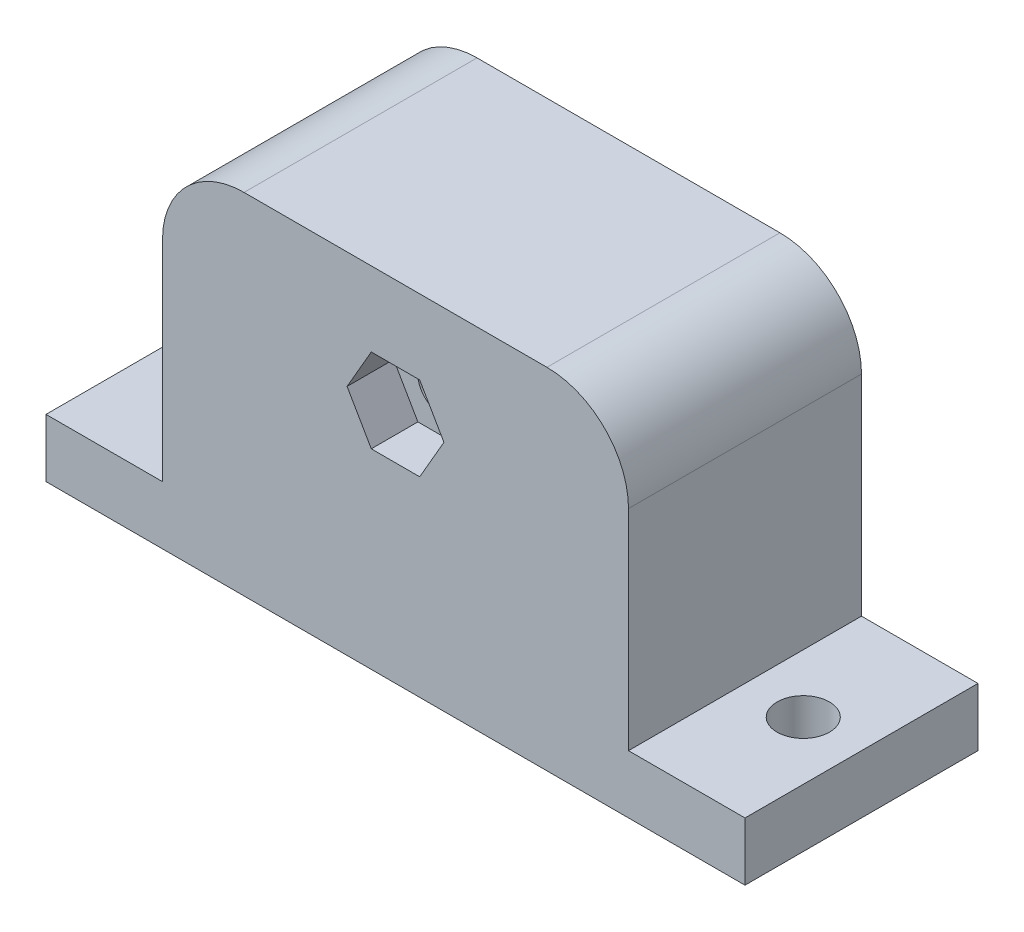
from build123d import *

# Parameters (mm, degrees)
SKETCH1_W               = 60
SKETCH1_H               = 20
SKETCH1_R               = 2.25
BOSS_EXTRUDE1_DEPTH     = 5
SKETCH2_W               = 40
SKETCH2_H               = 20
BOSS_EXTRUDE2_DEPTH     = 25
SKETCH3_R               = 2.1
CUT_EXTRUDE1_DEPTH      = 1
CUT_EXTRUDE1_DEPTH_BACK = 21
SKETCH4_R               = 3.75
CUT_EXTRUDE2_DEPTH      = 5
CUT_EXTRUDE3_DEPTH      = 4
FILLET1_R               = 7


with BuildPart() as part:
    # Sketch1 → Boss-Extrude1 (new body)
    with BuildSketch(Plane(origin=(0, 0, 0), x_dir=(1, 0, 0), z_dir=(0, 1, 0))):
        Rectangle(SKETCH1_W, SKETCH1_H)
        with Locations((-25, 0)):
            Circle(SKETCH1_R, mode=Mode.SUBTRACT)
        with Locations((25, 0)):
            Circle(SKETCH1_R, mode=Mode.SUBTRACT)
    extrude(amount=BOSS_EXTRUDE1_DEPTH)

    # Sketch2 → Boss-Extrude2 (add)
    with BuildSketch(Plane(origin=(0, 5, 0), x_dir=(1, 0, 0), z_dir=(0, 1, 0))):
        Rectangle(SKETCH2_W, SKETCH2_H)
    extrude(amount=BOSS_EXTRUDE2_DEPTH)

    # Sketch3 → Cut-Extrude1 (cut, two sides)
    with BuildSketch(Plane(origin=(0, 0, -10), x_dir=(-1, 0, 0), z_dir=(0, 0, -1))) as cut_extrude1_sk:
        with Locations((0, 20)):
            Circle(SKETCH3_R)
    extrude(amount=CUT_EXTRUDE1_DEPTH, mode=Mode.SUBTRACT)
    extrude(cut_extrude1_sk.sketch, amount=-CUT_EXTRUDE1_DEPTH_BACK, mode=Mode.SUBTRACT)

    # Sketch4 → Cut-Extrude2 (cut)
    with BuildSketch(Plane(origin=(0, 0, -10), x_dir=(-1, 0, 0), z_dir=(0, 0, -1))):
        with Locations((0, 20)):
            Circle(SKETCH4_R)
    extrude(amount=-CUT_EXTRUDE2_DEPTH, mode=Mode.SUBTRACT)

    # Sketch5 → Cut-Extrude3 (cut)
    with BuildSketch(Plane.XY.offset(10)):
        Polygon((2.078460969, 23.6), (-2.078460969, 23.6), (-4.156921938, 20), (-2.078460969, 16.4), (2.078460969, 16.4), (4.156921938, 20), align=None)
    extrude(amount=-CUT_EXTRUDE3_DEPTH, mode=Mode.SUBTRACT)

    # Fillet1
    fillet1_edges = [part.edges().sort_by_distance(p)[0] for p in [
        (-20, 30, 0),
        (20, 30, 0),
    ]]
    fillet(fillet1_edges, radius=FILLET1_R)


solid = part.part
